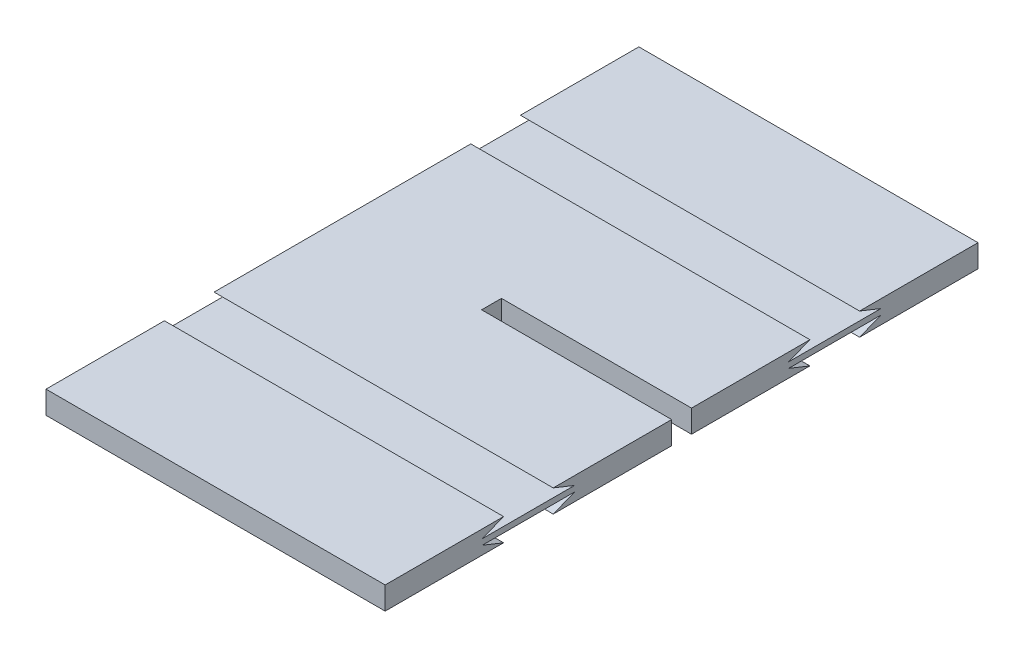
from build123d import *

# Parameters (mm, degrees)
BOSS_EXTRUDE1_DEPTH = 0.8
CUT_EXTRUDE1_START  = -5.3
CUT_EXTRUDE1_DEPTH  = 21.7
SKETCH3_W           = 15
SKETCH3_H           = 20.9
CUT_EXTRUDE2_DEPTH  = 1.8


with BuildPart() as part:
    # Sketch1 → Boss-Extrude1 (new body)
    with BuildSketch(Plane(origin=(0, 0, 0), x_dir=(1, 0, 0), z_dir=(0, 1, 0))):
        Polygon((13.478240741, 10.45), (-13.478240741, 10.45), (-13.478240741, -10.45), (13.478240741, -10.45), (13.478240741, -0.35), (-8.221759259, -0.35), (-8.221759259, 0.35), (13.478240741, 0.35), align=None)
    extrude(amount=BOSS_EXTRUDE1_DEPTH)

    # Sketch2 → Cut-Extrude1 (cut)
    with BuildSketch(Plane(origin=(13.478240741, 0, 0), x_dir=(0, 0, -1), z_dir=(1, 0, 0)).offset(CUT_EXTRUDE1_START)):
        Polygon((-7.025, 0.5), (-3.775, 0.5), (-4.525, 0.8), (-6.275, 0.8), align=None)
        Polygon((-7.025, 0.3), (-6.275, 0), (-4.525, 0), (-3.775, 0.3), align=None)
        Polygon((7.025, 0.3), (3.775, 0.3), (4.525, 0), (6.275, 0), align=None)
        Polygon((7.025, 0.5), (6.275, 0.8), (4.525, 0.8), (3.775, 0.5), align=None)
    extrude(amount=-CUT_EXTRUDE1_DEPTH, mode=Mode.SUBTRACT)

    # Sketch3 → Cut-Extrude2 (cut, through all)
    with BuildSketch(Plane(origin=(0, 0.8, 0), x_dir=(1, 0, 0), z_dir=(0, 1, 0))):
        with Locations((5.978240741, 0)):
            Rectangle(SKETCH3_W, SKETCH3_H)
    extrude(amount=-CUT_EXTRUDE2_DEPTH, mode=Mode.SUBTRACT)


solid = part.part
